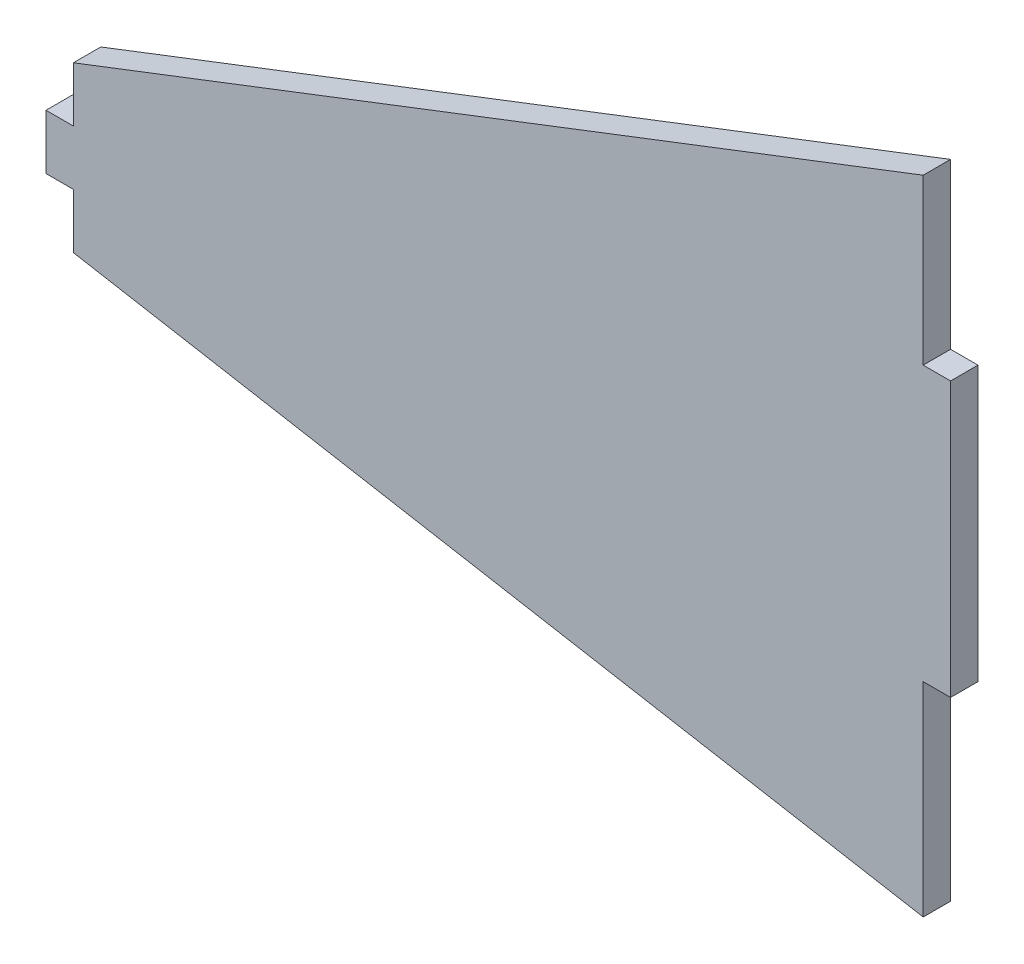
from build123d import *

# Parameters (mm, degrees)
SKETCH1_W           = 3.175
SKETCH1_H           = 31.75
BOSS_EXTRUDE2_DEPTH = 3.175
SKETCH2_W           = 3.175
SKETCH2_H           = 6.35
BOSS_EXTRUDE3_DEPTH = 3.175


with BuildPart() as part:
    # Sketch1 → Boss-Extrude2 (new body)
    with BuildSketch(Plane.XY):
        Polygon((0, 9.525), (0, -9.525), (98.425, -26.954443488), (98.425, -3.340380987), (98.425, 28.409619013), (98.425, 47.459619012), align=None)
        with Locations((100.0125, 12.534619013)):
            Rectangle(SKETCH1_W, SKETCH1_H)
    extrude(amount=BOSS_EXTRUDE2_DEPTH)

    # Sketch2 → Boss-Extrude3 (add)
    with BuildSketch(Plane.XY.offset(3.175)):
        with Locations((-1.5875, 0)):
            Rectangle(SKETCH2_W, SKETCH2_H)
    extrude(amount=-BOSS_EXTRUDE3_DEPTH)


solid = part.part
